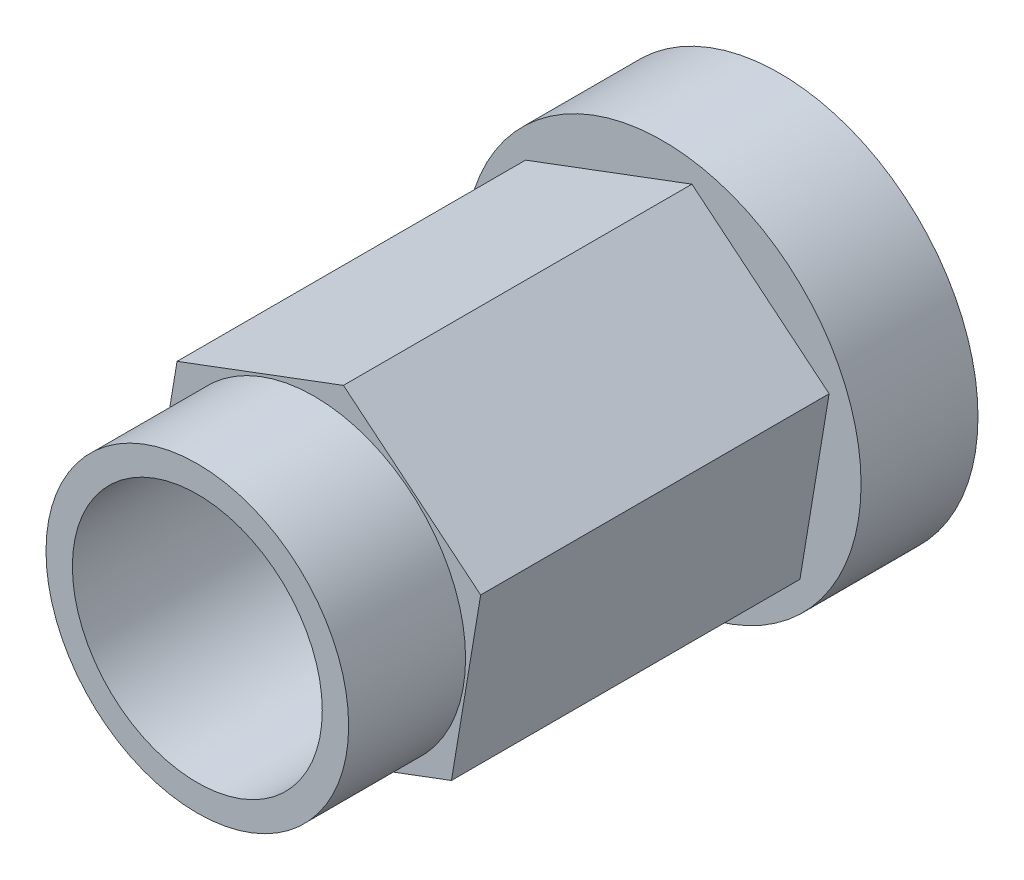
from build123d import *

# Parameters (mm, degrees)
BOSS_EXTRUDE1_DEPTH = 1.52
SKETCH4_R           = 0.66
BOSS_EXTRUDE3_DEPTH = 0.51
SKETCH2_R           = 0.865
BOSS_EXTRUDE2_DEPTH = 0.51
SKETCH3_R           = 0.545
CUT_EXTRUDE1_DEPTH  = 2.54


with BuildPart() as part:
    # Sketch1 → Boss-Extrude1 (new body)
    with BuildSketch(Plane.XY):
        Polygon((-0.725690397, -0.272026557), (-0.12726329, -0.764479598), (0.598427107, -0.492453041), (0.725690397, 0.272026557), (0.12726329, 0.764479598), (-0.598427107, 0.492453041), align=None)
    extrude(amount=BOSS_EXTRUDE1_DEPTH)

    # Sketch4 → Boss-Extrude3 (add)
    with BuildSketch(Plane.XY.offset(1.52)):
        Circle(SKETCH4_R)
    extrude(amount=BOSS_EXTRUDE3_DEPTH)

    # Sketch2 → Boss-Extrude2 (add)
    with BuildSketch(Plane(origin=(0, 0, 0), x_dir=(-1, 0, 0), z_dir=(0, 0, -1))):
        Circle(SKETCH2_R)
    extrude(amount=BOSS_EXTRUDE2_DEPTH)

    # Sketch3 → Cut-Extrude1 (cut)
    with BuildSketch(Plane(origin=(0, 0, -0.51), x_dir=(-1, 0, 0), z_dir=(0, 0, -1))):
        Circle(SKETCH3_R)
    extrude(amount=-CUT_EXTRUDE1_DEPTH, mode=Mode.SUBTRACT)


solid = part.part
